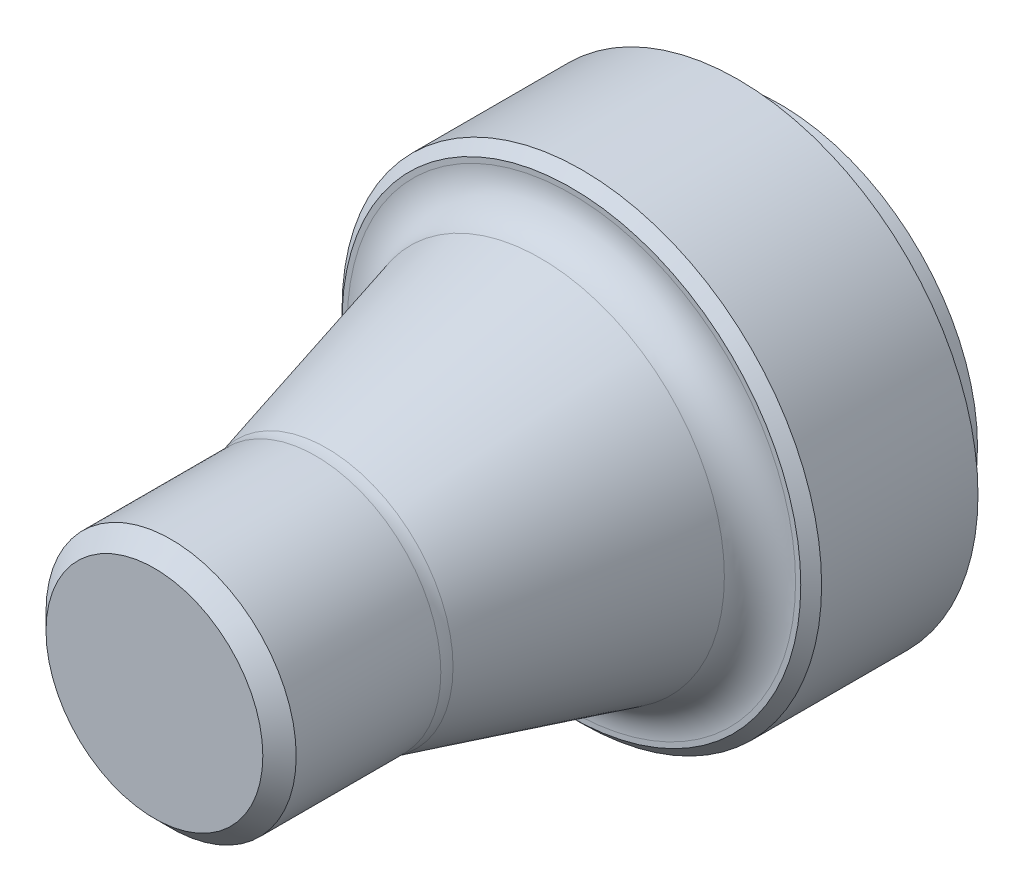
from build123d import *

# Parameters (mm, degrees)
SKETCH1_R           = 30.0863
BOSS_EXTRUDE1_DEPTH = 6.35
SKETCH2_R           = 36.5125
BOSS_EXTRUDE2_DEPTH = 25.4
SKETCH3_R           = 19.05
BOSS_EXTRUDE3_DEPTH = 38.1
DRAFT1_ANGLE        = 15
SKETCH4_R           = 19.05
BOSS_EXTRUDE4_DEPTH = 25.4
CHAMFER1_SIZE       = 2.54
FILLET1_R           = 6.35
CHAMFER2_SIZE       = 1.5875


with BuildPart() as part:
    # Sketch1 → Boss-Extrude1 (new body)
    with BuildSketch(Plane.XY):
        Circle(SKETCH1_R)
    extrude(amount=-BOSS_EXTRUDE1_DEPTH)

    # Sketch2 → Boss-Extrude2 (add)
    with BuildSketch(Plane.XY):
        Circle(SKETCH2_R)
    extrude(amount=BOSS_EXTRUDE2_DEPTH)

    # Sketch3 → Boss-Extrude3 (add)
    with BuildSketch(Plane.XY.offset(25.4)):
        Circle(SKETCH3_R)
    extrude(amount=BOSS_EXTRUDE3_DEPTH)

    # Draft1
    draft1_faces = [part.faces().sort_by_distance(p)[0] for p in [
        (-19.05, 0, 44.45),
    ]]
    draft(draft1_faces, Plane.XY.offset(63.5), DRAFT1_ANGLE)

    # Sketch4 → Boss-Extrude4 (add)
    with BuildSketch(Plane.XY.offset(63.5)):
        Circle(SKETCH4_R)
    extrude(amount=BOSS_EXTRUDE4_DEPTH)

    # Chamfer1
    chamfer1_edges = [part.edges().sort_by_distance(p)[0] for p in [
        (-19.05, 0, 88.9),
    ]]
    chamfer(chamfer1_edges, length=CHAMFER1_SIZE)

    # Fillet1
    fillet1_edges = [part.edges().sort_by_distance(p)[0] for p in [
        (-19.05, 0, 63.5),
        (-29.258864232, 0, 25.4),
    ]]
    fillet(fillet1_edges, radius=FILLET1_R)

    # Chamfer2
    chamfer2_edges = [part.edges().sort_by_distance(p)[0] for p in [
        (-36.5125, 0, 25.4),
    ]]
    chamfer(chamfer2_edges, length=CHAMFER2_SIZE)


solid = part.part
